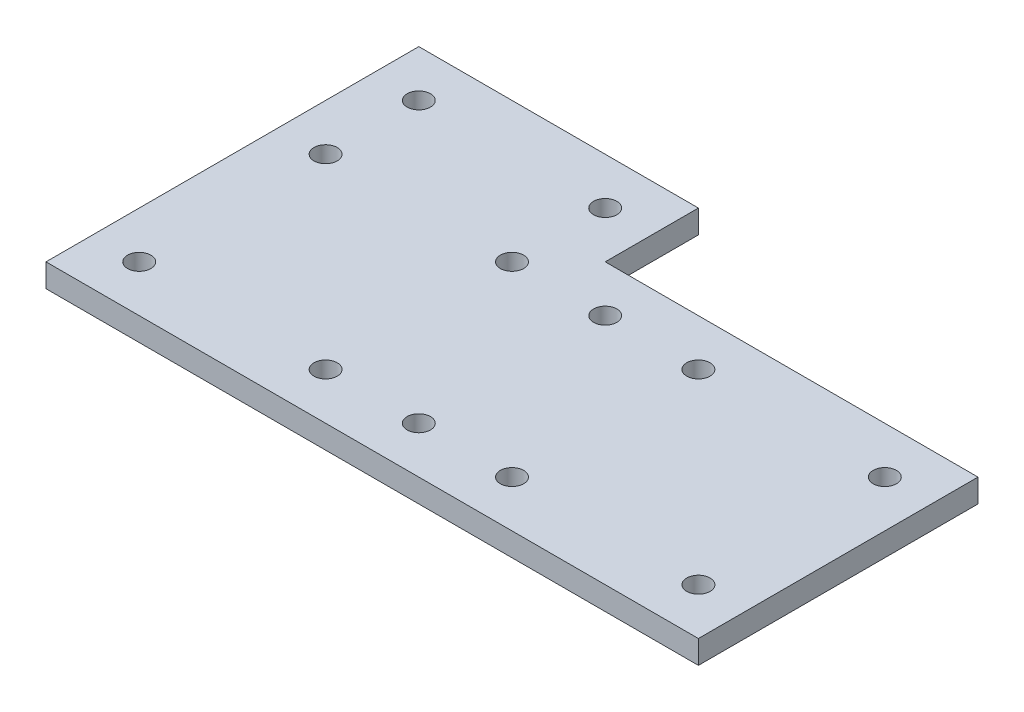
from build123d import *

# Parameters (mm, degrees)
BOSS_EXTRUDE1_DEPTH = 3.175
SKETCH2_R           = 1.5875
CUT_EXTRUDE1_DEPTH  = 4.175


with BuildPart() as part:
    # Sketch1 → Boss-Extrude1 (new body)
    with BuildSketch(Plane(origin=(0, 0, 0), x_dir=(1, 0, 0), z_dir=(0, 1, 0))):
        Polygon((0, 50.8), (0, 0), (88.9, 0), (88.9, 38.1), (38.1, 38.1), (38.1, 50.8), align=None)
    extrude(amount=BOSS_EXTRUDE1_DEPTH)

    # Sketch2 → Cut-Extrude1 (cut, through all)
    with BuildSketch(Plane(origin=(0, 3.175, 0), x_dir=(1, 0, 0), z_dir=(0, 1, 0))):
        with Locations((6.35, 44.45)):
            Circle(SKETCH2_R)
        with Locations((31.75, 44.45)):
            Circle(SKETCH2_R)
        with Locations((31.75, 31.75)):
            Circle(SKETCH2_R)
        with Locations((6.35, 31.75)):
            Circle(SKETCH2_R)
        with Locations((6.35, 6.35)):
            Circle(SKETCH2_R)
        with Locations((31.75, 6.35)):
            Circle(SKETCH2_R)
        with Locations((82.55, 6.35)):
            Circle(SKETCH2_R)
        with Locations((82.55, 31.75)):
            Circle(SKETCH2_R)
        with Locations((57.15, 31.75)):
            Circle(SKETCH2_R)
        with Locations((57.15, 6.35)):
            Circle(SKETCH2_R)
        with Locations((44.45, 6.35)):
            Circle(SKETCH2_R)
        with Locations((44.45, 31.75)):
            Circle(SKETCH2_R)
    extrude(amount=-CUT_EXTRUDE1_DEPTH, mode=Mode.SUBTRACT)


solid = part.part
